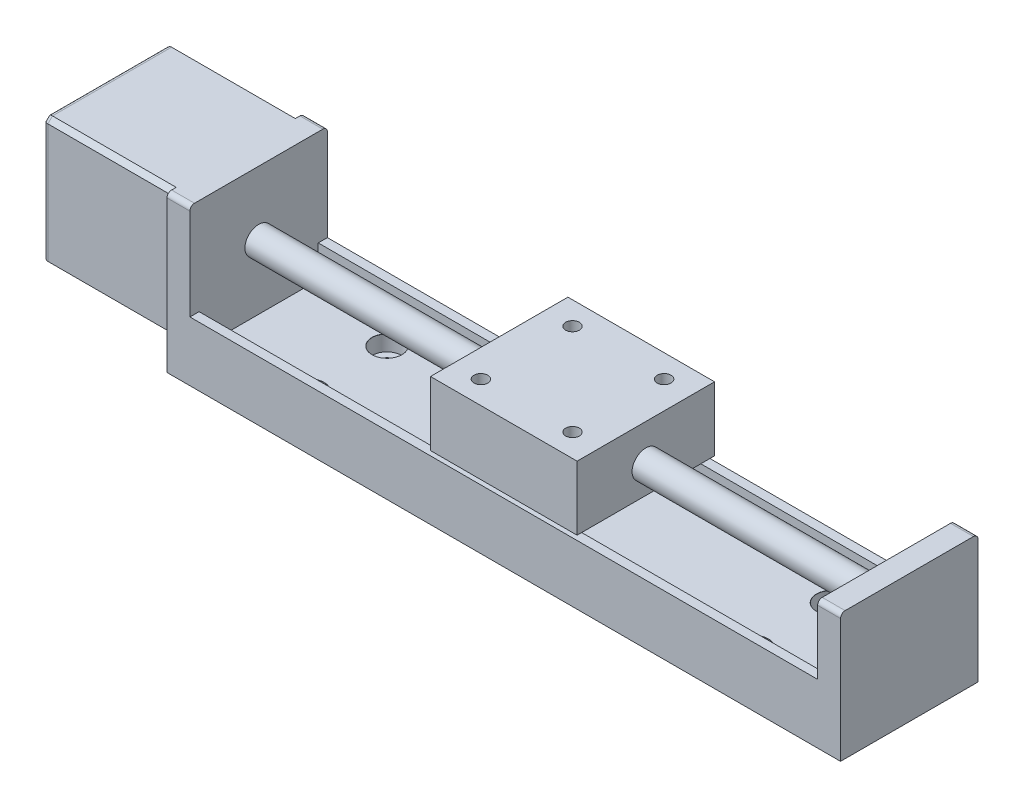
from build123d import *

# Parameters (mm, degrees)
BOSS_EXTRUDE1_DEPTH                          = 15
SKETCH2_W                                    = 137
SKETCH2_H                                    = 26
CUT_EXTRUDE1_DEPTH                           = 7
SKETCH3_R                                    = 3
BOSS_EXTRUDE2_DEPTH                          = 142
CUT_EXTRUDE2_DEPTH                           = 35
CHAMFER1_SIZE                                = 1
FILLET1_R                                    = 1
FILLET2_R                                    = 1
CBORE_FOR_M3_HEX_SOCKET_HEAD_CAP_SCR_2_COUNT = 2
CBORE_FOR_M3_HEX_SOCKET_HEAD_CAP_SCR_2_PITCH = 17
CBORE_FOR_M3_HEX_SOCKET_HEAD_CAP_SCR_3_COUNT = 2
CBORE_FOR_M3_HEX_SOCKET_HEAD_CAP_SCR_3_PITCH = 97
CBORE_FOR_M3_HEX_SOCKET_HEAD_CAP_SCR_4_COUNT = 2
CBORE_FOR_M3_HEX_SOCKET_HEAD_CAP_SCR_4_PITCH = 98.478424033
SKETCH7_W                                    = 32
SKETCH7_H                                    = 30
BOSS_EXTRUDE3_DEPTH                          = 14
HOLE1_D                                      = 3
HOLE1_DEPTH                                  = 6


with BuildPart() as part:
    # Sketch1 → Boss-Extrude1 (new body, symmetric)
    with BuildSketch(Plane.XY):
        Polygon((-103.5, 34), (-103.5, 6), (-73.5, 6), (-73.5, 0), (73.5, 0), (73.5, 28), (68.5, 28), (68.5, 13), (-68.5, 13), (-68.5, 34), align=None)
    extrude(amount=BOSS_EXTRUDE1_DEPTH, both=True)

    # Sketch2 → Cut-Extrude1 (cut)
    with BuildSketch(Plane(origin=(0, 13, 0), x_dir=(1, 0, 0), z_dir=(0, 1, 0))):
        Rectangle(SKETCH2_W, SKETCH2_H)
    extrude(amount=-CUT_EXTRUDE1_DEPTH, mode=Mode.SUBTRACT)

    # Sketch3 → Boss-Extrude2 (add)
    with BuildSketch(Plane(origin=(73.5, 0, 0), x_dir=(0, 0, -1), z_dir=(1, 0, 0))):
        with Locations((0, 20)):
            Circle(SKETCH3_R)
    extrude(amount=-BOSS_EXTRUDE2_DEPTH)

    # Sketch4 → Cut-Extrude2 (cut, through all)
    with BuildSketch(Plane(origin=(0, 34, 0), x_dir=(1, 0, 0), z_dir=(0, 1, 0))):
        Polygon((-73.5, -15), (-73.5, -14), (-101.5, -14), (-101.5, 14), (-73.5, 14), (-73.5, 15), (-103.5, 15), (-103.5, -15), align=None)
    extrude(amount=-CUT_EXTRUDE2_DEPTH, mode=Mode.SUBTRACT)

    # Chamfer1
    chamfer1_edges = [part.edges().sort_by_distance(p)[0] for p in [
        (-87.5, 6, -14),
        (-87.5, 6, 14),
        (-87.5, 34, 14),
        (-87.5, 34, -14),
    ]]
    chamfer(chamfer1_edges, length=CHAMFER1_SIZE)

    # Fillet1
    fillet1_edges = [part.edges().sort_by_distance(p)[0] for p in [
        (-101.5, 34, 0),
        (-101.5, 20, -14),
        (-101.5, 33.5, 13.5),
        (-101.5, 33.5, -13.5),
        (-101.5, 6.5, -13.5),
        (-101.5, 6.5, 13.5),
        (-101.5, 6, 0),
        (-101.5, 20, 14),
    ]]
    fillet(fillet1_edges, radius=FILLET1_R)

    # Fillet2
    fillet2_edges = [part.edges().sort_by_distance(p)[0] for p in [
        (-71, 34, -15),
        (71, 28, -15),
        (71, 28, 15),
        (-71, 34, 15),
    ]]
    fillet(fillet2_edges, radius=FILLET2_R)

    # Sketch6 → CBORE for M3 Hex Socket Head Cap Screw1 (revolve, cut)
    with BuildSketch(Plane(origin=(-48.5, 6, -8.006829487), x_dir=(0, 0, 1), z_dir=(1, 0, 0))):
        Polygon((0, 0), (0, 6), (1.7, 6), (1.7, 3.4), (3.25, 3.4), (3.25, 0.025), (3.275, 0), align=None)
    cbore_for_m3_hex_socket_head_cap_screw1 = revolve(axis=Axis((-48.5, 12.35, -8.006829487), (0, -1, 0)), mode=Mode.SUBTRACT)

    # CBORE for M3 Hex Socket Head Cap Scr 2: CBORE for M3 Hex Socket Head Cap Screw1 ×2
    with Locations(*[(0, 0, i * CBORE_FOR_M3_HEX_SOCKET_HEAD_CAP_SCR_2_PITCH) for i in range(1, CBORE_FOR_M3_HEX_SOCKET_HEAD_CAP_SCR_2_COUNT)]):
        add(cbore_for_m3_hex_socket_head_cap_screw1, mode=Mode.SUBTRACT)

    # CBORE for M3 Hex Socket Head Cap Scr 3: CBORE for M3 Hex Socket Head Cap Screw1 ×2
    with Locations(*[(i * CBORE_FOR_M3_HEX_SOCKET_HEAD_CAP_SCR_3_PITCH, 0, 0) for i in range(1, CBORE_FOR_M3_HEX_SOCKET_HEAD_CAP_SCR_3_COUNT)]):
        add(cbore_for_m3_hex_socket_head_cap_screw1, mode=Mode.SUBTRACT)

    # CBORE for M3 Hex Socket Head Cap Scr 4: CBORE for M3 Hex Socket Head Cap Screw1 ×2
    with Locations(*[Vector(0.984987331, 0, 0.172626646) * (i * CBORE_FOR_M3_HEX_SOCKET_HEAD_CAP_SCR_4_PITCH) for i in range(1, CBORE_FOR_M3_HEX_SOCKET_HEAD_CAP_SCR_4_COUNT)]):
        add(cbore_for_m3_hex_socket_head_cap_screw1, mode=Mode.SUBTRACT)

    # Sketch7 → Boss-Extrude3 (add)
    with BuildSketch(Plane(origin=(0, 28, 0), x_dir=(1, 0, 0), z_dir=(0, 1, 0))):
        Rectangle(SKETCH7_W, SKETCH7_H)
    extrude(amount=-BOSS_EXTRUDE3_DEPTH)

    # Hole1
    with Locations(Plane(origin=(0, 28, 0), x_dir=(1, 0, 0), z_dir=(0, 1, 0))):
        with Locations((10, 10), (10, -10), (-10, -10), (-10, 10)):
            Hole(HOLE1_D / 2, depth=HOLE1_DEPTH)


solid = part.part
